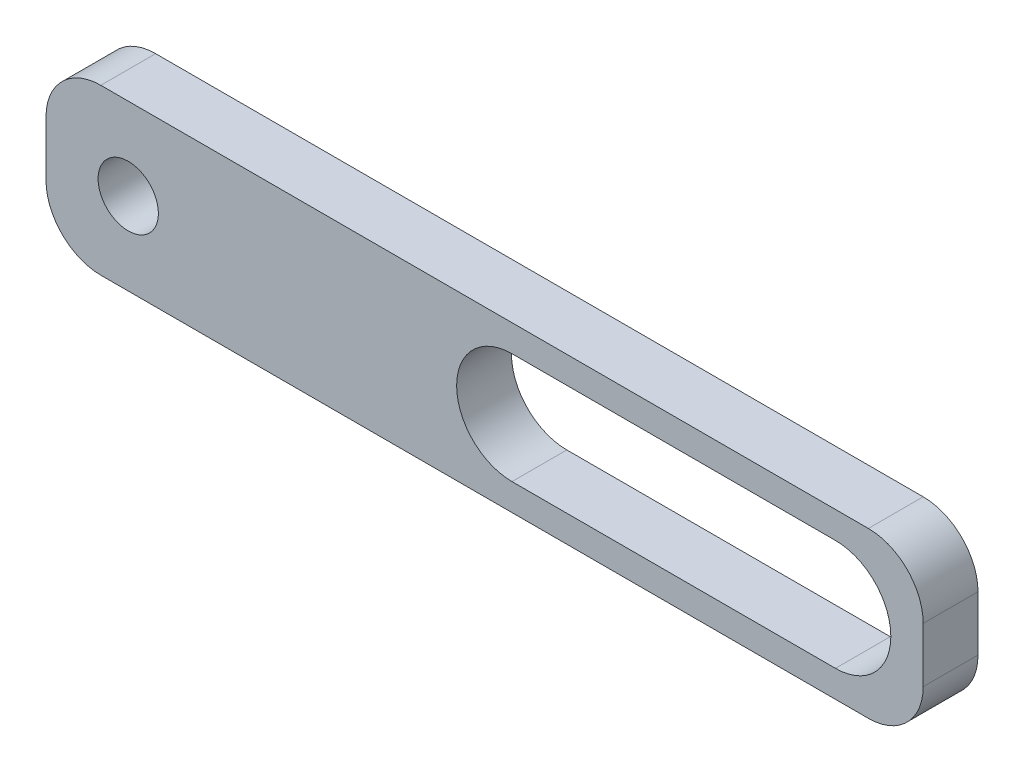
from build123d import *

# Parameters (mm, degrees)
SKETCH1_R           = 2.75
BOSS_EXTRUDE1_DEPTH = 5


with BuildPart() as part:
    # Sketch1 → Boss-Extrude1 (new body)
    with BuildSketch(Plane.XY):
        with BuildLine():
            Line((0, 5), (0, 10))
            ThreePointArc((0, 10), (1.464466094, 13.535533906), (5, 15))
            Line((5, 15), (75, 15))
            ThreePointArc((75, 15), (78.535533906, 13.535533906), (80, 10))
            Line((80, 10), (80, 5))
            ThreePointArc((80, 5), (78.535533906, 1.464466094), (75, 0))
            Line((75, 0), (5, 0))
            ThreePointArc((5, 0), (1.464466094, 1.464466094), (0, 5))
        make_face()
        with Locations((7.5, 7.5)):
            Circle(SKETCH1_R, mode=Mode.SUBTRACT)
        with BuildLine():
            Line((42.5, 12.55), (72, 12.55))
            ThreePointArc((72, 12.55), (77.05, 7.5), (72, 2.45))
            Line((72, 2.45), (42.5, 2.45))
            ThreePointArc((42.5, 2.45), (37.45, 7.5), (42.5, 12.55))
        make_face(mode=Mode.SUBTRACT)
    extrude(amount=BOSS_EXTRUDE1_DEPTH)


solid = part.part
